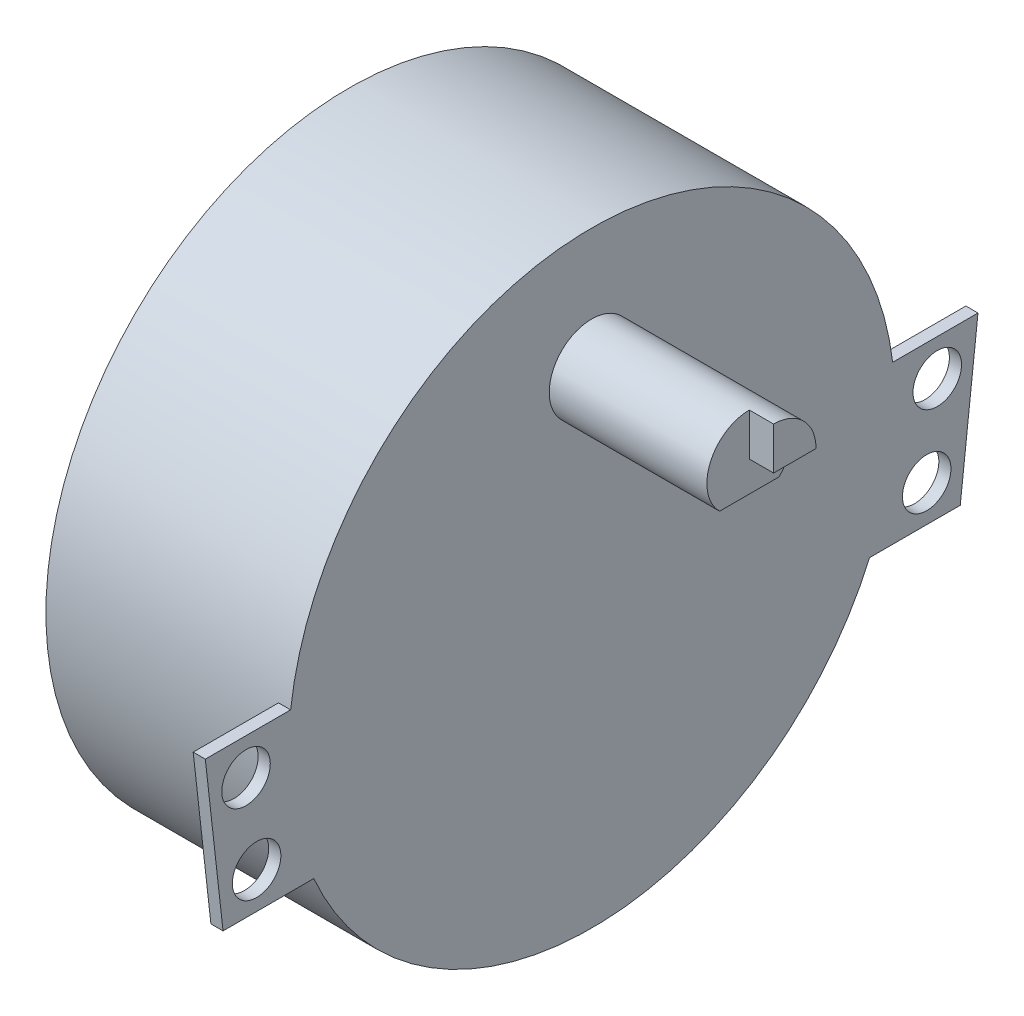
from build123d import *

# Parameters (mm, degrees)
SKETCH1_R           = 25
BOSS_EXTRUDE1_DEPTH = 20
BOSS_EXTRUDE2_DEPTH = 15
SKETCH3_R           = 2
BOSS_EXTRUDE3_DEPTH = 1
CUT_EXTRUDE1_DEPTH  = 2


with BuildPart() as part:
    # Sketch1 → Boss-Extrude1 (new body)
    with BuildSketch(Plane(origin=(0, 0, 0), x_dir=(0, 0, -1), z_dir=(1, 0, 0))):
        Circle(SKETCH1_R)
    extrude(amount=BOSS_EXTRUDE1_DEPTH)

    # Sketch2 → Boss-Extrude2 (add)
    with BuildSketch(Plane(origin=(20, 0, 0), x_dir=(0, 0, -1), z_dir=(1, 0, 0))):
        with BuildLine():
            Line((-2.449489743, 12.5), (2.449489743, 12.5))
            ThreePointArc((2.449489743, 12.5), (0, 18.5), (-2.449489743, 12.5))
        make_face()
    extrude(amount=BOSS_EXTRUDE2_DEPTH)

    # Sketch3 → Boss-Extrude3 (add)
    with BuildSketch(Plane(origin=(20, 0, 0), x_dir=(0, 0, -1), z_dir=(1, 0, 0))):
        with BuildLine():
            Line((-31.854729385, 3), (-30.392824551, -10))
            Line((-30.392824551, -10), (-22.912878475, -10))
            ThreePointArc((-22.912878475, -10), (-24.735426905, -3.62748616), (-24.819347292, 3))
            Line((-24.819347292, 3), (-31.854729385, 3))
        make_face()
        with Locations((-28.497841918, 0)):
            Circle(SKETCH3_R, mode=Mode.SUBTRACT)
        with Locations((-27.624753284, -7)):
            Circle(SKETCH3_R, mode=Mode.SUBTRACT)
        with BuildLine():
            Line((31.854729385, 3), (30.392824551, -10))
            Line((30.392824551, -10), (22.912878475, -10))
            ThreePointArc((22.912878475, -10), (24.735426905, -3.62748616), (24.819347292, 3))
            Line((24.819347292, 3), (31.854729385, 3))
        make_face()
        with Locations((27.624753284, -7)):
            Circle(SKETCH3_R, mode=Mode.SUBTRACT)
        with Locations((28.497841918, 0)):
            Circle(SKETCH3_R, mode=Mode.SUBTRACT)
    extrude(amount=-BOSS_EXTRUDE3_DEPTH)

    # Sketch4 → Cut-Extrude1 (cut)
    with BuildSketch(Plane(origin=(35, 0, 0), x_dir=(0, 0, -1), z_dir=(1, 0, 0))):
        with BuildLine():
            Line((0, 15), (3.5, 15))
            ThreePointArc((3.5, 15), (-2.474873734, 12.525126266), (0, 18.5))
            Line((0, 18.5), (0, 15))
        make_face()
    extrude(amount=-CUT_EXTRUDE1_DEPTH, mode=Mode.SUBTRACT)


solid = part.part
